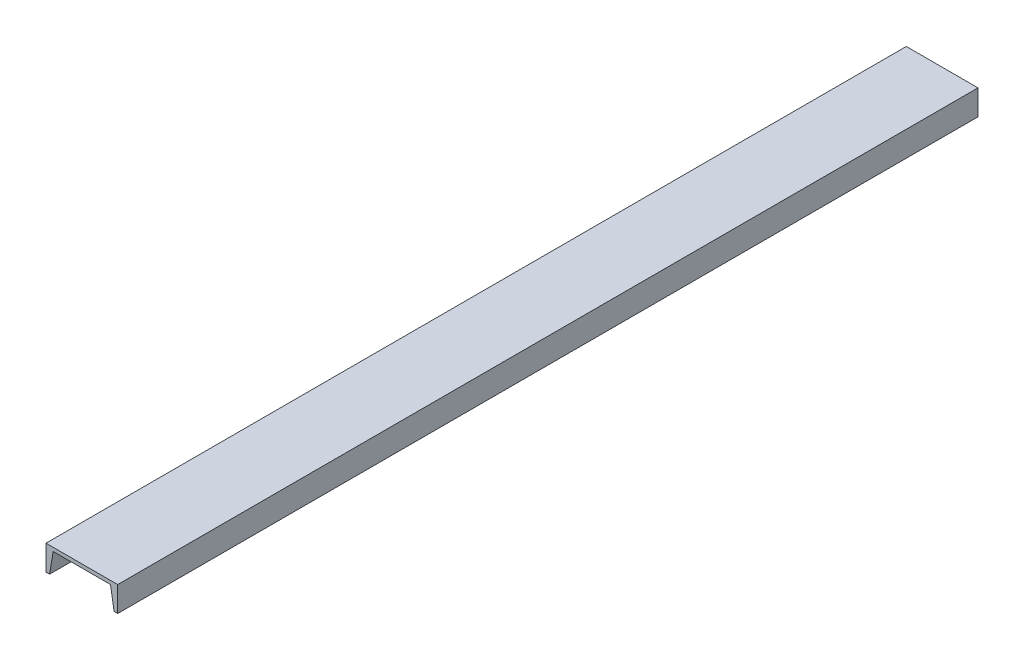
from build123d import *

# Parameters (mm, degrees)
BOSS_EXTRUDE1_DEPTH = 1524


with BuildPart() as part:
    # Sketch1 → Boss-Extrude1 (new body)
    with BuildSketch(Plane.XY):
        Polygon((0, 0), (127, 0), (127, -44.45), (120.65, -44.45), (114.3, -6.35), (12.7, -6.35), (6.35, -44.45), (0, -44.45), align=None)
    extrude(amount=BOSS_EXTRUDE1_DEPTH)


solid = part.part
